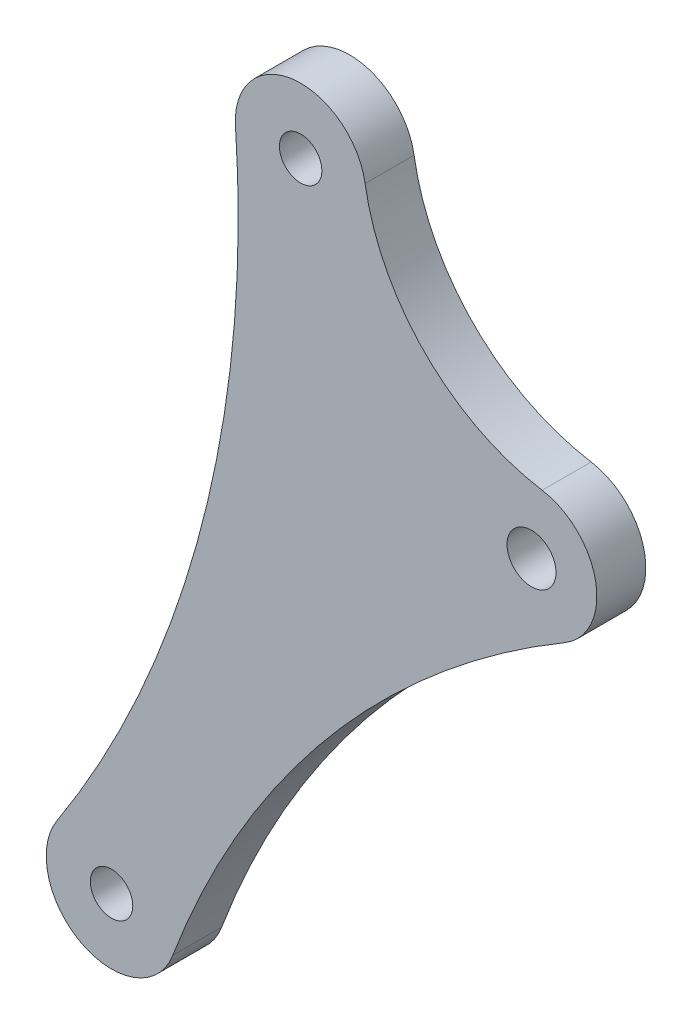
from build123d import *

# Parameters (mm, degrees)
MODEL_R             = 1.300000002
MODEL_R_2           = 1.500000003
BOSS_EXTRUDE1_DEPTH = 3


with BuildPart() as part:
    # Model → Boss-Extrude1 (new body)
    with BuildSketch(Plane.XY):
        with BuildLine():
            ThreePointArc((57.913301974, 61.156066436), (53.502068591, 64.480518249), (49.975907149, 60.228795621))
            ThreePointArc((49.975907149, 60.228795621), (47.94925686, 38.176029403), (39.030226452, 17.905787524))
            ThreePointArc((39.030226452, 17.905787524), (40.582105252, 12.156647321), (46.129664865, 14.321254263))
            ThreePointArc((46.129664865, 14.321254263), (55.685249441, 30.675009463), (70.137725469, 42.917576284))
            ThreePointArc((70.137725469, 42.917576284), (72.036216679, 47.098079429), (68.754469063, 50.309155261))
            ThreePointArc((68.754469063, 50.309155261), (61.589228346, 53.988877576), (57.913301974, 61.156066436))
        make_face()
        with Locations((42.384943632, 15.727344886)):
            Circle(MODEL_R, mode=Mode.SUBTRACT)
        with Locations((53.966045378, 60.508142659)):
            Circle(MODEL_R, mode=Mode.SUBTRACT)
        with Locations((68.104570202, 46.36236227)):
            Circle(MODEL_R_2, mode=Mode.SUBTRACT)
    extrude(amount=BOSS_EXTRUDE1_DEPTH)


solid = part.part
